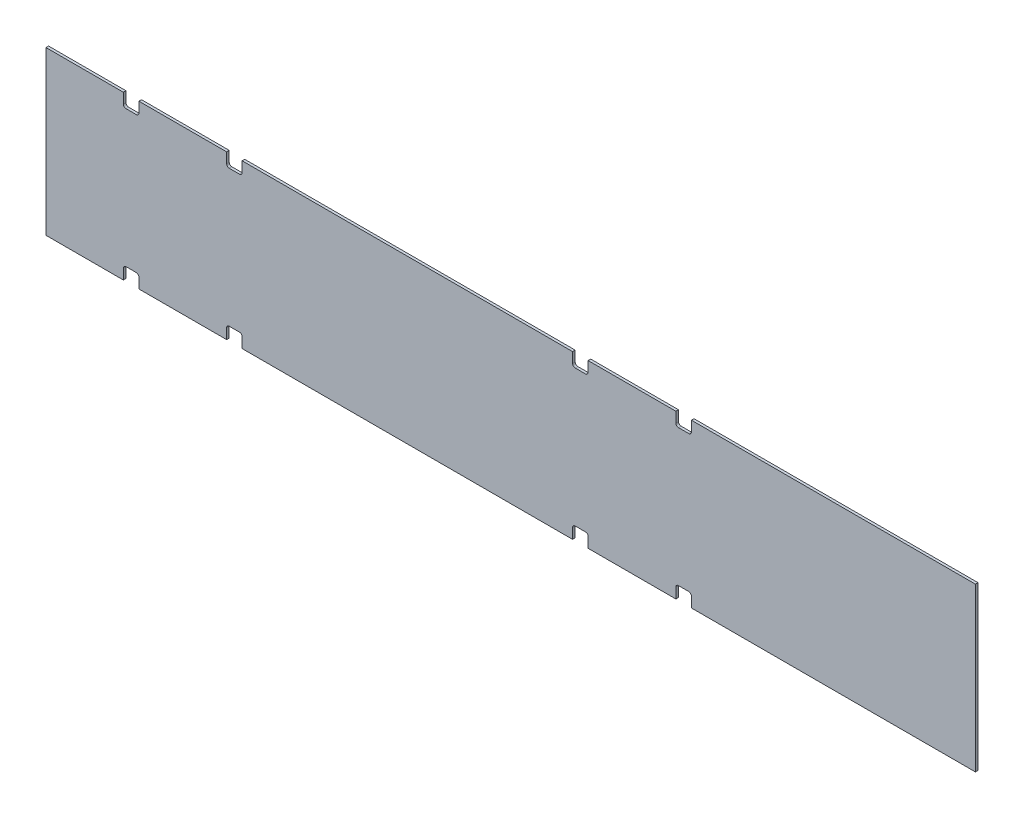
from build123d import *

# Parameters (mm, degrees)
SKETCH1_W            = 1143
SKETCH1_H            = 200.025
BOSS_EXTRUDE1_DEPTH  = 3.175
SKETCH3_W            = 19.05
SKETCH3_H            = 15.875
CUT_EXTRUDE1_DEPTH   = 4.175
FILLET1_R            = 3.175
FILLET1_OF_MIRROR2_R = 3.175


with BuildPart() as part:
    # Sketch1 → Boss-Extrude1 (new body)
    with BuildSketch(Plane.XY):
        Rectangle(SKETCH1_W, SKETCH1_H)
    extrude(amount=BOSS_EXTRUDE1_DEPTH)

    # Sketch3 → Cut-Extrude1 (cut, through all)
    with BuildSketch(Plane.XY.offset(3.175)):
        with Locations((-466.8139, -92.075)):
            Rectangle(SKETCH3_W, SKETCH3_H)
        with Locations((-339.8139, -92.075)):
            Rectangle(SKETCH3_W, SKETCH3_H)
        with Locations((85.6361, -92.075)):
            Rectangle(SKETCH3_W, SKETCH3_H)
        with Locations((212.6361, -92.075)):
            Rectangle(SKETCH3_W, SKETCH3_H)
    cut_extrude1 = extrude(amount=-CUT_EXTRUDE1_DEPTH, mode=Mode.SUBTRACT)

    # Fillet1
    fillet1_edges = [part.edges().sort_by_distance(p)[0] for p in [
        (-476.3389, -84.1375, 1.5875),
        (-457.2889, -84.1375, 1.5875),
        (-349.3389, -84.1375, 1.5875),
        (-330.2889, -84.1375, 1.5875),
        (76.1111, -84.1375, 1.5875),
        (95.1611, -84.1375, 1.5875),
        (203.1111, -84.1375, 1.5875),
        (222.1611, -84.1375, 1.5875),
    ]]
    fillet(fillet1_edges, radius=FILLET1_R)

    # Mirror2: Cut-Extrude1 across plane
    add(cut_extrude1.mirror(Plane.ZX), mode=Mode.SUBTRACT)

    # Fillet1 of Mirror2
    fillet1_of_mirror2_edges = [part.edges().sort_by_distance(p)[0] for p in [
        (-476.3389, 84.1375, 1.5875),
        (-457.2889, 84.1375, 1.5875),
        (-349.3389, 84.1375, 1.5875),
        (-330.2889, 84.1375, 1.5875),
        (76.1111, 84.1375, 1.5875),
        (95.1611, 84.1375, 1.5875),
        (203.1111, 84.1375, 1.5875),
        (222.1611, 84.1375, 1.5875),
    ]]
    fillet(fillet1_of_mirror2_edges, radius=FILLET1_OF_MIRROR2_R)


solid = part.part
